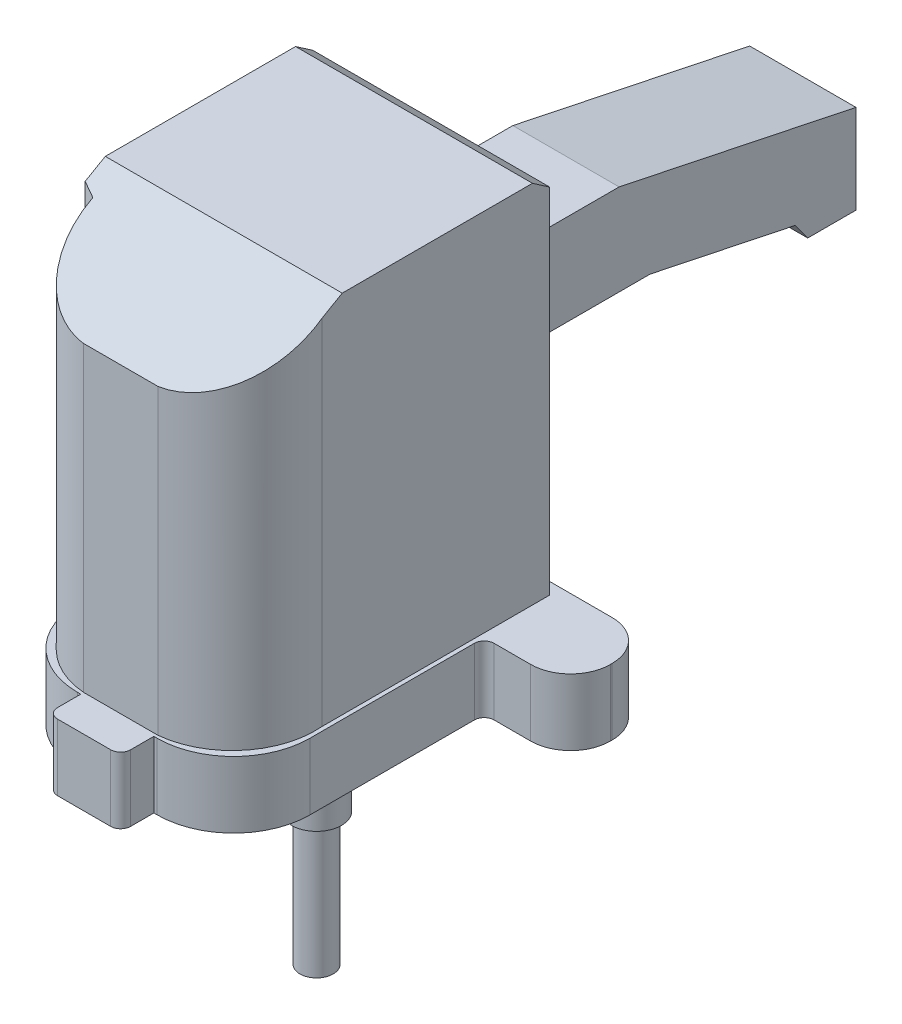
from build123d import *

# Parameters (mm, degrees)
SKETCH_1_R               = 2
SKETCH_1_R_2             = 10
EXTRUDE_1_DEPTH          = 20
SKETCH_2_R               = 25
SKETCH_2_R_2             = 12
EXTRUDE_2_DEPTH          = 2
EXTRUDE_3_DEPTH          = 110
SKETCH_4_OUTSIDE_W       = 274.729
SKETCH_4_OUTSIDE_H       = 190.272
CUT_EXTRUDE_5_DEPTH      = 62
CUT_EXTRUDE_5_DEPTH_BACK = 62
SKETCH_5_R               = 7.5
EXTRUDE_4_DEPTH          = 55
SKETCH_6_R               = 5
EXTRUDE_5_DEPTH          = 40


with BuildPart() as part:
    # Эскиз1 → Бобышка-Вытянуть1 (new body)
    with BuildSketch(Plane(origin=(0, 0, 0), x_dir=(1, 0, 0), z_dir=(0, 1, 0))):
        with BuildLine():
            Line((35, 12.5), (35, -37))
            ThreePointArc((35, -37), (28.263455967, -53.263455967), (12, -60))
            Line((12, -60), (11, -60))
            Line((11, -60), (11, -67))
            ThreePointArc((11, -67), (10.121320344, -69.121320344), (8, -70))
            Line((8, -70), (-8, -70))
            ThreePointArc((-8, -70), (-10.121320344, -69.121320344), (-11, -67))
            Line((-11, -67), (-11, -60))
            Line((-11, -60), (-12, -60))
            ThreePointArc((-12, -60), (-28.263455967, -53.263455967), (-35, -37))
            Line((-35, -37), (-35, -35))
            Line((-35, -35), (-37, -35))
            ThreePointArc((-37, -35), (-39.121320344, -34.121320344), (-40, -32))
            Line((-40, -32), (-40, 12.5))
            ThreePointArc((-40, 12.5), (-40.878679656, 14.621320344), (-43, 15.5))
            Line((-43, 15.5), (-49, 15.5))
            ThreePointArc((-49, 15.5), (-57.485281374, 19.014718626), (-61, 27.5))
            Line((-61, 27.5), (-61, 28))
            ThreePointArc((-61, 28), (-57.485281374, 36.485281374), (-49, 40))
            Line((-49, 40), (49, 40))
            ThreePointArc((49, 40), (57.485281374, 36.485281374), (61, 28))
            Line((61, 28), (61, 27.5))
            ThreePointArc((61, 27.5), (57.485281374, 19.014718626), (49, 15.5))
            Line((49, 15.5), (38, 15.5))
            ThreePointArc((38, 15.5), (35.878679656, 14.621320344), (35, 12.5))
        make_face()
        with Locations((27.5, 27.5)):
            Circle(SKETCH_1_R, mode=Mode.SUBTRACT)
        with Locations((-27.5, 27.5)):
            Circle(SKETCH_1_R, mode=Mode.SUBTRACT)
        with Locations((-27.5, -27.5)):
            Circle(SKETCH_1_R, mode=Mode.SUBTRACT)
        with Locations((27.5, -27.5)):
            Circle(SKETCH_1_R, mode=Mode.SUBTRACT)
        Circle(SKETCH_1_R_2, mode=Mode.SUBTRACT)
    extrude(amount=EXTRUDE_1_DEPTH)

    # Эскиз2 → Бобышка-Вытянуть2 (add)
    with BuildSketch(Plane.XZ):
        Circle(SKETCH_2_R)
        Circle(SKETCH_2_R_2, mode=Mode.SUBTRACT)
    extrude(amount=EXTRUDE_2_DEPTH)

    # Эскиз3 → Бобышка-Вытянуть3 (add)
    with BuildSketch(Plane(origin=(0, 20, 0), x_dir=(1, 0, 0), z_dir=(0, 1, 0))):
        with BuildLine():
            Line((-37.583733624, -32.103535028), (-37.583733624, 36.457416544))
            Line((-37.583733624, 36.457416544), (-16, 36.457416544))
            Line((-16, 36.457416544), (-16, 146.457416544))
            Line((-16, 146.457416544), (16, 146.457416544))
            Line((16, 146.457416544), (16, 36.457416544))
            Line((16, 36.457416544), (33.766635678, 36.457416544))
            Line((33.766635678, 36.457416544), (33.766635678, -32.103535028))
            ThreePointArc((33.766635678, -32.103535028), (28.080470389, -50.220903637), (11.304482379, -59.11684357))
            Line((11.304482379, -59.11684357), (-11, -59.11684357))
            ThreePointArc((-11, -59.11684357), (-27.23731375, -51.101673534), (-33.326201299, -34.048264581))
            Line((-33.326201299, -34.048264581), (-37.583733624, -32.103535028))
        make_face()
    extrude(amount=EXTRUDE_3_DEPTH)

    # Эскиз4 outside → Вырез-Вытянуть5 (cut, two sides)
    with BuildSketch(Plane(origin=(0, 0, 0), x_dir=(0, 0, -1), z_dir=(1, 0, 0))) as cut_extrude_5_sk:
        with Locations((38.2285, 64)):
            Rectangle(SKETCH_4_OUTSIDE_W, SKETCH_4_OUTSIDE_H)
        Polygon((-59.11684357, 111.009140669), (-59.11684357, 20), (-70, 20), (-70, 0), (-25.61704501, 0), (-25.61704501, -2.465693048), (25.5, -2.465693048), (25.5, 0), (40, 0), (40, 20), (36.457416544, 20), (36.457416544, 70.826498743), (84.412407161, 70.826498743), (128.193178806, 61.67378586), (131.933723793, 56.499947934), (146.457416544, 56.499947934), (146.457416544, 83.32776512), (75.121913518, 98.241010205), (43.39244845, 98.241010205), (36.457416544, 102.079664685), (36.457416544, 126.416047598), (31.26241492, 130), (-26.036858243, 130), align=None, mode=Mode.SUBTRACT)
    extrude(amount=CUT_EXTRUDE_5_DEPTH, mode=Mode.SUBTRACT)
    extrude(cut_extrude_5_sk.sketch, amount=-CUT_EXTRUDE_5_DEPTH_BACK, mode=Mode.SUBTRACT)

    # Эскиз5 → Бобышка-Вытянуть4 (add)
    with BuildSketch(Plane.XZ.offset(-20)):
        Circle(SKETCH_5_R)
    extrude(amount=EXTRUDE_4_DEPTH)

    # Эскиз6 → Бобышка-Вытянуть5 (add)
    with BuildSketch(Plane.XZ.offset(35)):
        Circle(SKETCH_6_R)
    extrude(amount=EXTRUDE_5_DEPTH)


solid = part.part
